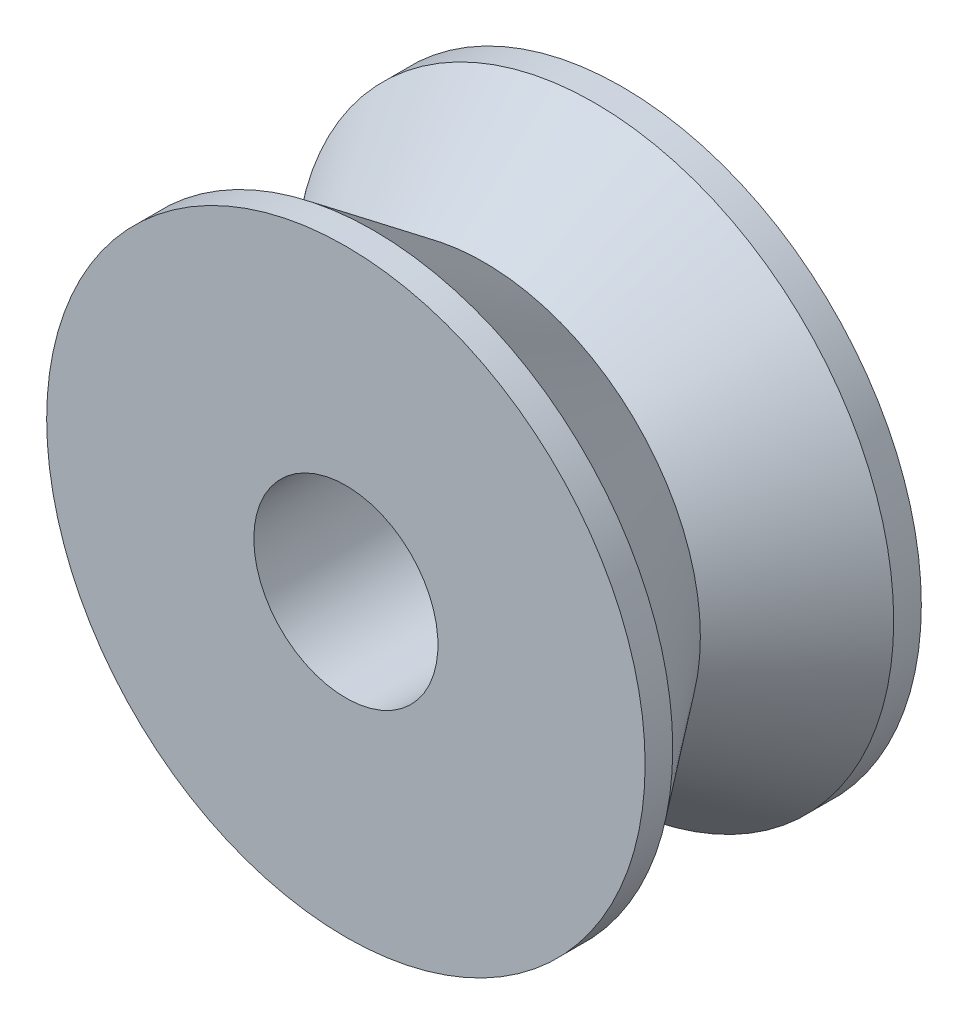
from build123d import *


with BuildPart() as part:
    # 草图1 → 旋转1 (revolve)
    with BuildSketch(Plane(origin=(0, 0, 0), x_dir=(0, 0, -1), z_dir=(1, 0, 0))):
        Polygon((-3, 2), (3, 2), (3, 6.5), (2.4, 6.5), (0, 4.7), (-2.4, 6.5), (-3, 6.5), align=None)
    revolve(axis=Axis((0, 0, 0), (0, 0, 1)))


solid = part.part
